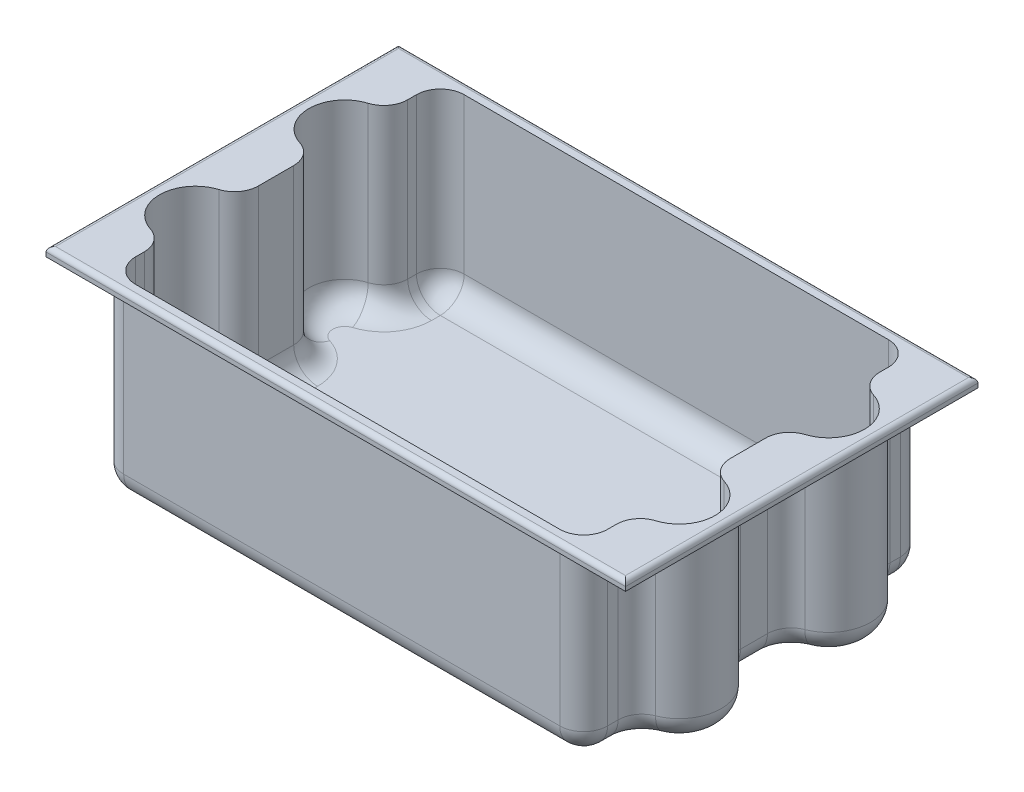
from build123d import *

# Parameters (mm, degrees)
SKETCH1_W           = 615.95
SKETCH1_H           = 374.65
BOSS_EXTRUDE1_DEPTH = 200.025
CUT_EXTRUDE1_DEPTH  = 190.5
SKETCH3_W           = 514.35
SKETCH3_H           = 6.35
CUT_EXTRUDE2_DEPTH  = 190.5
CUT_EXTRUDE3_DEPTH  = 190.5
FILLET1_R           = 25.4
FILLET2_R           = 25.4
FILLET3_R           = 25.4
FILLET4_R           = 25.4
FILLET5_R           = 5.08


with BuildPart() as part:
    # Sketch1 → Boss-Extrude1 (new body)
    with BuildSketch(Plane(origin=(0, 0, 0), x_dir=(1, 0, 0), z_dir=(0, 1, 0))):
        Rectangle(SKETCH1_W, SKETCH1_H)
    extrude(amount=BOSS_EXTRUDE1_DEPTH)

    # Sketch2 → Cut-Extrude1 (cut)
    with BuildSketch(Plane.XZ):
        with BuildLine():
            Line((-257.175, 123.825), (-257.175, 187.325))
            Line((-257.175, 187.325), (-307.975, 187.325))
            Line((-307.975, 187.325), (-307.975, -187.325))
            Line((-307.975, -187.325), (-257.175, -187.325))
            Line((-257.175, -187.325), (-257.175, -174.625))
            Line((-257.175, -174.625), (-257.175, -123.825))
            ThreePointArc((-257.175, -123.825), (-301.625, -79.375), (-257.175, -34.925))
            Line((-257.175, -34.925), (-257.175, 34.925))
            ThreePointArc((-257.175, 34.925), (-301.625, 79.375), (-257.175, 123.825))
        make_face()
    cut_extrude1 = extrude(amount=-CUT_EXTRUDE1_DEPTH, mode=Mode.SUBTRACT)

    # Mirror1: Cut-Extrude1 across plane
    add(cut_extrude1.mirror(Plane(origin=(0, 0, 0), x_dir=(0, 0, 1), z_dir=(1, 0, 0))), mode=Mode.SUBTRACT)

    # Sketch3 → Cut-Extrude2 (cut)
    with BuildSketch(Plane.XZ):
        with Locations((0, 184.15)):
            Rectangle(SKETCH3_W, SKETCH3_H)
    cut_extrude2 = extrude(amount=-CUT_EXTRUDE2_DEPTH, mode=Mode.SUBTRACT)

    # Mirror2: Cut-Extrude2 across plane
    add(cut_extrude2.mirror(Plane.XY), mode=Mode.SUBTRACT)

    # Sketch5 → Cut-Extrude3 (cut)
    with BuildSketch(Plane(origin=(0, 200.025, 0), x_dir=(1, 0, 0), z_dir=(0, 1, 0))):
        with BuildLine():
            Line((-250.825, 41.807893377), (-250.825, -41.807893377))
            ThreePointArc((-250.825, -41.807893377), (-295.275, -79.375), (-250.825, -116.942106623))
            Line((-250.825, -116.942106623), (-250.825, -174.625))
            Line((-250.825, -174.625), (250.825, -174.625))
            Line((250.825, -174.625), (250.825, -116.942106623))
            ThreePointArc((250.825, -116.942106623), (295.275, -79.375), (250.825, -41.807893377))
            Line((250.825, -41.807893377), (250.825, 41.807893377))
            ThreePointArc((250.825, 41.807893377), (295.275, 79.375), (250.825, 116.942106623))
            Line((250.825, 116.942106623), (250.825, 174.625))
            Line((250.825, 174.625), (-250.825, 174.625))
            Line((-250.825, 174.625), (-250.825, 116.942106623))
            ThreePointArc((-250.825, 116.942106623), (-295.275, 79.375), (-250.825, 41.807893377))
        make_face()
    extrude(amount=-CUT_EXTRUDE3_DEPTH, mode=Mode.SUBTRACT)

    # Fillet1
    fillet1_edges = [part.edges().sort_by_distance(p)[0] for p in [
        (-257.175, 95.25, -123.825),
        (-257.175, 95.25, 123.825),
        (-257.175, 95.25, 34.925),
        (-257.175, 95.25, -34.925),
        (257.175, 95.25, -123.825),
        (257.175, 95.25, -34.925),
        (257.175, 95.25, 34.925),
        (257.175, 95.25, 123.825),
        (-257.175, 95.25, 180.975),
        (257.175, 95.25, 180.975),
        (-257.175, 95.25, -180.975),
        (257.175, 95.25, -180.975),
    ]]
    fillet(fillet1_edges, radius=FILLET1_R)

    # Fillet2
    fillet2_edges = [part.edges().sort_by_distance(p)[0] for p in [
        (250.825, 104.775, 174.625),
        (-250.825, 104.775, 174.625),
        (-250.825, 104.775, 116.942106623),
        (-250.825, 104.775, 41.807893377),
        (-250.825, 104.775, -41.807893377),
        (-250.825, 104.775, -116.942106623),
        (-250.825, 104.775, -174.625),
        (250.825, 104.775, -174.625),
        (250.825, 104.775, -116.942106623),
        (250.825, 104.775, -41.807893377),
        (250.825, 104.775, 41.807893377),
        (250.825, 104.775, 116.942106623),
    ]]
    fillet(fillet2_edges, radius=FILLET2_R)

    # Fillet3
    fillet3_edges = [part.edges().sort_by_distance(p)[0] for p in [
        (0, 9.525, -174.625),
        (250.825, 9.525, -144.587569645),
        (-295.275, 9.525, -79.375),
        (-250.825, 9.525, 0),
        (-295.275, 9.525, 79.375),
        (-250.825, 9.525, 144.587569645),
        (0, 9.525, 174.625),
        (250.825, 9.525, 144.587569645),
        (295.275, 9.525, 79.375),
        (250.825, 9.525, 0),
        (295.275, 9.525, -79.375),
        (-250.825, 9.525, -144.587569645),
        (243.385512242, 9.525, 167.185512242),
        (-243.385512242, 9.525, 167.185512242),
        (-243.385512242, 9.525, -167.185512242),
        (243.385512242, 9.525, -167.185512242),
        (-255.746865319, 9.525, -124.923296641),
        (-255.746865319, 9.525, -33.826703359),
        (-255.746865319, 9.525, 33.826703359),
        (-255.746865319, 9.525, 124.923296641),
        (255.746865319, 9.525, -124.923296641),
        (255.746865319, 9.525, -33.826703359),
        (255.746865319, 9.525, 33.826703359),
        (255.746865319, 9.525, 124.923296641),
    ]]
    fillet(fillet3_edges, radius=FILLET3_R)

    # Fillet4
    fillet4_edges = [part.edges().sort_by_distance(p)[0] for p in [
        (257.175, 0, 150.009068682),
        (0, 0, -180.975),
        (257.175, 0, -150.009068682),
        (301.625, 0, -79.375),
        (257.175, 0, 0),
        (301.625, 0, 79.375),
        (0, 0, 180.975),
        (-257.175, 0, 150.009068682),
        (-301.625, 0, 79.375),
        (-257.175, 0, 0),
        (-301.625, 0, -79.375),
        (-257.175, 0, -150.009068682),
        (-249.735512242, 0, 173.535512242),
        (-249.735512242, 0, -173.535512242),
        (249.735512242, 0, -173.535512242),
        (249.735512242, 0, 173.535512242),
        (261.601640274, 0, 130.115605063),
        (261.601640274, 0, 28.634394937),
        (261.601640274, 0, -28.634394937),
        (261.601640274, 0, -130.115605063),
        (-261.601640274, 0, -130.115605063),
        (-261.601640274, 0, 28.634394937),
        (-261.601640274, 0, -28.634394937),
        (-261.601640274, 0, 130.115605063),
    ]]
    fillet(fillet4_edges, radius=FILLET4_R)

    # Fillet5
    fillet5_edges = [part.edges().sort_by_distance(p)[0] for p in [
        (307.975, 200.025, 0),
        (0, 200.025, -187.325),
        (-307.975, 200.025, 0),
        (0, 200.025, 187.325),
    ]]
    fillet(fillet5_edges, radius=FILLET5_R)


solid = part.part
